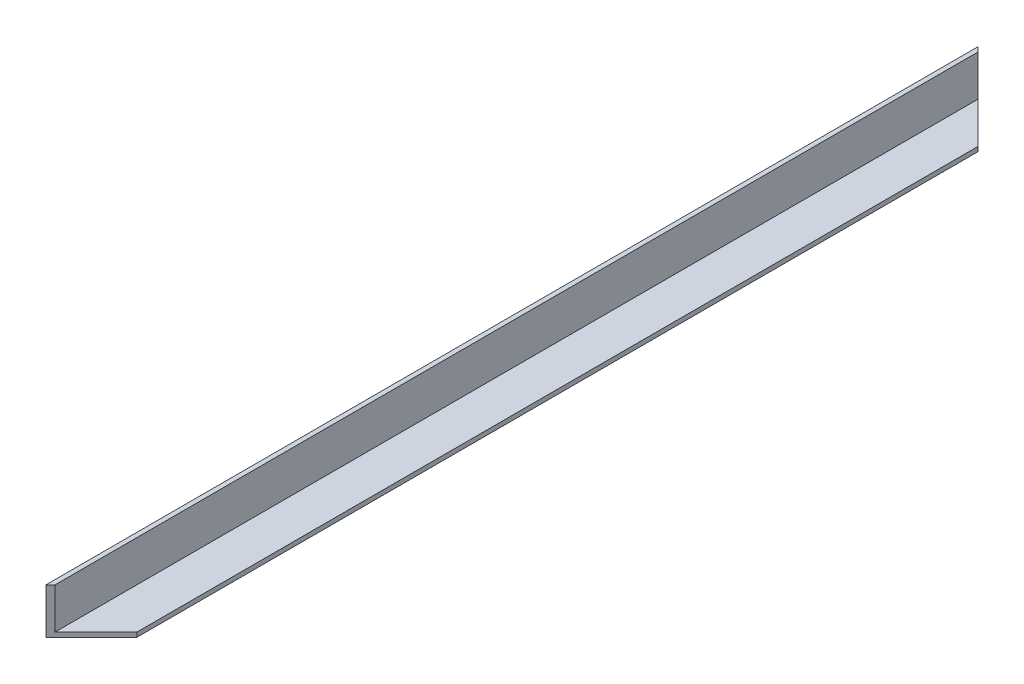
from build123d import *

# Parameters (mm, degrees)
BOSS_EXTRUDE1_DEPTH = 410
CUT_EXTRUDE1_DEPTH  = 21


with BuildPart() as part:
    # Sketch1 → Boss-Extrude1 (new body)
    with BuildSketch(Plane.XY):
        Polygon((0, 20), (0, 0), (20, 0), (20, 2), (2, 2), (2, 20), align=None)
    extrude(amount=BOSS_EXTRUDE1_DEPTH)

    # Sketch2 → Cut-Extrude1 (cut, through all)
    with BuildSketch(Plane(origin=(0, 20, 0), x_dir=(1, 0, 0), z_dir=(0, 1, 0))):
        Polygon((0, 0), (20, -20), (20, 0), align=None)
        Polygon((0, -410), (20, -390), (20, -410), align=None)
    extrude(amount=-CUT_EXTRUDE1_DEPTH, mode=Mode.SUBTRACT)


solid = part.part
